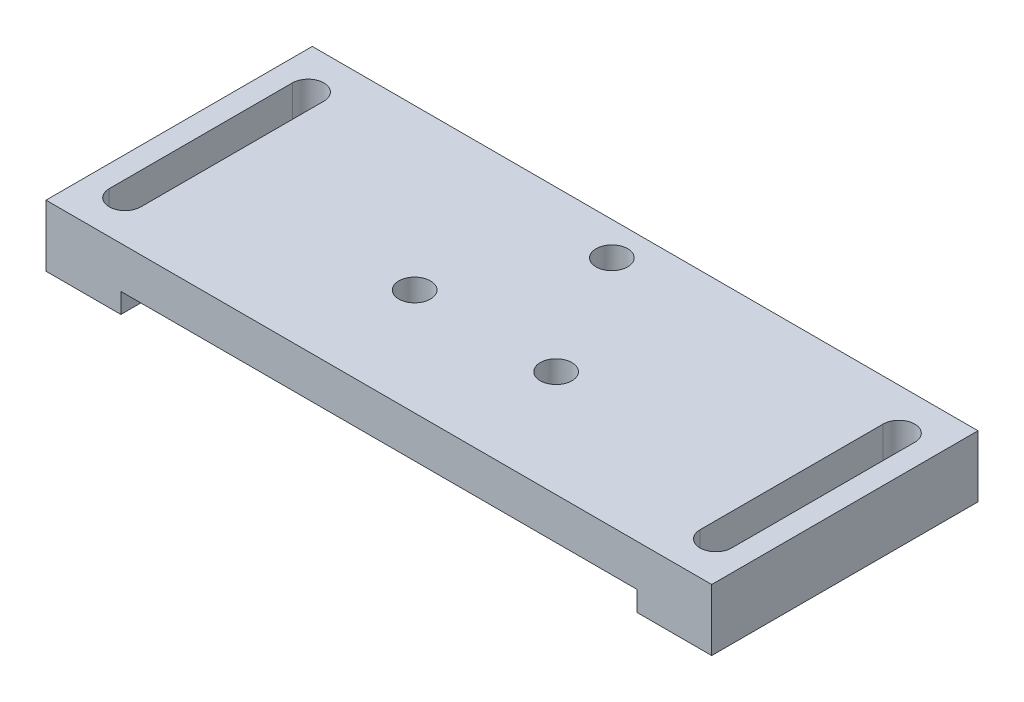
from build123d import *

# Parameters (mm, degrees)
SKETCH1_W           = 40
SKETCH1_H           = 16
BOSS_EXTRUDE1_DEPTH = 2.5
SKETCH2_W           = 4.5
SKETCH2_H           = 16
BOSS_EXTRUDE2_DEPTH = 1.2
CUT_EXTRUDE1_DEPTH  = 4.7
SKETCH4_R           = 0.95
CUT_EXTRUDE2_DEPTH  = 4.7


with BuildPart() as part:
    # Sketch1 → Boss-Extrude1 (new body)
    with BuildSketch(Plane(origin=(0, 0, 0), x_dir=(1, 0, 0), z_dir=(0, 1, 0))):
        Rectangle(SKETCH1_W, SKETCH1_H)
    extrude(amount=BOSS_EXTRUDE1_DEPTH)

    # Sketch2 → Boss-Extrude2 (add)
    with BuildSketch(Plane.XZ):
        with Locations((-17.75, 0)):
            Rectangle(SKETCH2_W, SKETCH2_H)
    boss_extrude2 = extrude(amount=BOSS_EXTRUDE2_DEPTH)

    # Sketch3 → Cut-Extrude1 (cut, through all)
    with BuildSketch(Plane.XZ.offset(1.2)):
        with BuildLine():
            Line((-16.8, 5.5), (-16.8, -5.5))
            ThreePointArc((-16.8, -5.5), (-17.75, -6.45), (-18.7, -5.5))
            Line((-18.7, -5.5), (-18.7, 5.5))
            ThreePointArc((-18.7, 5.5), (-17.75, 6.45), (-16.8, 5.5))
        make_face()
    cut_extrude1 = extrude(amount=-CUT_EXTRUDE1_DEPTH, mode=Mode.SUBTRACT)

    # Mirror1: Boss-Extrude2, Cut-Extrude1 across plane
    add(boss_extrude2.mirror(Plane(origin=(0, 0, 0), x_dir=(0, 0, 1), z_dir=(1, 0, 0))))
    add(cut_extrude1.mirror(Plane(origin=(0, 0, 0), x_dir=(0, 0, 1), z_dir=(1, 0, 0))), mode=Mode.SUBTRACT)

    # Sketch4 → Cut-Extrude2 (cut, through all)
    with BuildSketch(Plane(origin=(0, 2.5, 0), x_dir=(1, 0, 0), z_dir=(0, 1, 0))):
        with Locations((4.25, -1.6)):
            Circle(SKETCH4_R)
        with Locations((-4.25, -1.6)):
            Circle(SKETCH4_R)
        with Locations((0, 6)):
            Circle(SKETCH4_R)
    extrude(amount=-CUT_EXTRUDE2_DEPTH, mode=Mode.SUBTRACT)


solid = part.part
